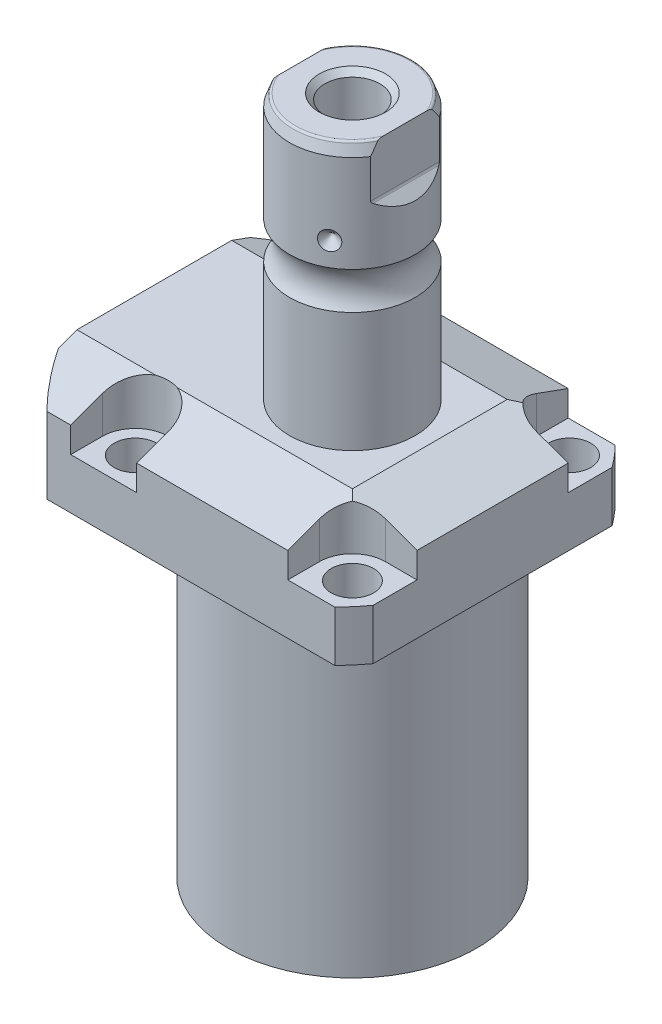
from build123d import *

# Parameters (mm, degrees)
SKETCH1_W                = 70.866
SKETCH1_H                = 85.496
EXTRUDE1_DEPTH           = 104.4448
SKETCH2_OUTSIDE_W        = 117.986
SKETCH2_OUTSIDE_H        = 103.356
SKETCH2_OUTSIDE_R        = 50.8
CUT_EXTRUDE1_DEPTH       = 105.4448
SKETCH3_W                = 45.1992
SKETCH3_H                = 79.4258
FILLET1_R                = 0.381
CUT_EXTRUDE2_DEPTH       = 12.243
CUT_EXTRUDE9_START       = -51.063
CUT_EXTRUDE9_DEPTH       = 87.496
CUT_EXTRUDE7_DEPTH       = 36.433
CUT_EXTRUDE7_DEPTH_BACK  = 36.433
SKETCH10_R               = 1.1811
SKETCH17_W               = 5.3594
SKETCH17_H               = 12.776
HOLE1_AT_2_COUNT         = 2
HOLE1_AT_2_PITCH         = 54.864
HOLE1_AT_3_COUNT         = 2
HOLE1_AT_3_PITCH         = 77.589412886
HOLE1_AT_4_COUNT         = 2
HOLE1_AT_4_PITCH         = 54.864
CHAMFER1_SIZE            = 0.635
FILLET2_R                = 0.635
CIRPATTERN1_COUNT        = 3
CUT_EXTRUDE10_DEPTH      = 36.433
CUT_EXTRUDE10_DEPTH_BACK = 36.433
CHAMFER2_SIZE            = 1.4351


with BuildPart() as part:
    # Sketch1 → Extrude1 (new body)
    with BuildSketch(Plane(origin=(0, 0, 0), x_dir=(0, 0, 1), z_dir=(0, -1, 0))):
        with Locations((0, 7.315)):
            Rectangle(SKETCH1_W, SKETCH1_H)
    extrude(amount=-EXTRUDE1_DEPTH)

    # Sketch2 outside → Cut-Extrude1 (cut, through all)
    with BuildSketch(Plane.XZ):
        with Locations((-7.315, 0)):
            Rectangle(SKETCH2_OUTSIDE_W, SKETCH2_OUTSIDE_H)
        with Locations((-5.4102, 0)):
            Circle(SKETCH2_OUTSIDE_R, mode=Mode.SUBTRACT)
    extrude(amount=-CUT_EXTRUDE1_DEPTH, mode=Mode.SUBTRACT)

    # Sketch3 → Cut-Revolve1 (revolve, cut)
    with BuildSketch(Plane(origin=(0, 0, 0), x_dir=(0, 0, -1), z_dir=(1, 0, 0))):
        with Locations((53.9941, 39.7129)):
            Rectangle(SKETCH3_W, SKETCH3_H)
    revolve(axis=Axis((0, -93.345, 0), (0, 1, 0)), mode=Mode.SUBTRACT)

    # Fillet1
    fillet1_edges = [part.edges().sort_by_distance(p)[0] for p in [
        (0, 79.4258, 31.3945),
    ]]
    fillet(fillet1_edges, radius=FILLET1_R)

    # Sketch4 → Cut-Extrude2 (cut)
    with BuildSketch(Plane(origin=(0, 104.4448, 0), x_dir=(-1, 0, 0), z_dir=(0, 1, 0))):
        with BuildLine():
            Line((-19.1008, -35.433), (-19.1008, -27.432))
            ThreePointArc((-19.1008, -27.432), (-21.540951985, -21.540951985), (-27.432, -19.1008))
            Line((-27.432, -19.1008), (-35.433, -19.1008))
            Line((-35.433, -19.1008), (-35.433, -35.433))
            Line((-35.433, -35.433), (-19.1008, -35.433))
        make_face()
        with BuildLine():
            Line((35.7632, -35.433), (19.1008, -35.433))
            Line((19.1008, -35.433), (19.1008, -27.432))
            ThreePointArc((19.1008, -27.432), (27.432, -19.1008), (35.7632, -27.432))
            Line((35.7632, -27.432), (35.7632, -35.433))
        make_face()
        with BuildLine():
            Line((19.1008, 35.433), (19.1008, 27.432))
            ThreePointArc((19.1008, 27.432), (27.432, 19.1008), (35.7632, 27.432))
            Line((35.7632, 27.432), (35.7632, 35.433))
            Line((35.7632, 35.433), (19.1008, 35.433))
        make_face()
        with BuildLine():
            Line((-27.432, 19.1008), (-35.433, 19.1008))
            Line((-35.433, 19.1008), (-35.433, 35.433))
            Line((-35.433, 35.433), (-19.1008, 35.433))
            Line((-19.1008, 35.433), (-19.1008, 27.432))
            ThreePointArc((-19.1008, 27.432), (-21.540951985, 21.540951985), (-27.432, 19.1008))
        make_face()
    extrude(amount=-CUT_EXTRUDE2_DEPTH, mode=Mode.SUBTRACT)

    # Sketch5 → Cut-Extrude9 (cut)
    with BuildSketch(Plane(origin=(0, 0, 0), x_dir=(0, 0, -1), z_dir=(1, 0, 0)).offset(CUT_EXTRUDE9_START)):
        Polygon((-19.558, 104.4448), (-35.433, 98.666772531), (-35.433, 104.4448), align=None)
    cut_extrude9 = extrude(amount=CUT_EXTRUDE9_DEPTH, mode=Mode.SUBTRACT)

    # Mirror1: Cut-Extrude9 across plane
    add(cut_extrude9.mirror(Plane.XY), mode=Mode.SUBTRACT)

    # Sketch9 → Cut-Extrude7 (cut, two sides)
    with BuildSketch(Plane.XY) as cut_extrude7_sk:
        Polygon((19.558, 104.4448), (35.433, 98.666772531), (35.433, 104.4448), align=None)
    extrude(amount=CUT_EXTRUDE7_DEPTH, mode=Mode.SUBTRACT)
    extrude(cut_extrude7_sk.sketch, amount=-CUT_EXTRUDE7_DEPTH_BACK, mode=Mode.SUBTRACT)

    # Sketch20 → Cut-Revolve4 (revolve, cut)
    with BuildSketch(Plane(origin=(-35.0774, 88.9, -18.1102), x_dir=(0, 1, 0), z_dir=(1, 0, 0)), mode=Mode.PRIVATE) as cut_revolve4_sk:
        Polygon((-9.4742, 38.3413), (-8.0264, 38.3413), (-8.0264, 35.8902), (-7.0104, 35.8902), (-7.0104, 33.8836), (3.9624, 33.8836), (3.9624, 32.639), (-9.4742, 32.639), align=None)
    cut_revolve4 = revolve(cut_revolve4_sk.sketch.rotate(Axis((-35.0774, 81.620304954, 14.5288), (0, 1, 0)), 180), axis=Axis((-35.0774, 81.620304954, 14.5288), (0, 1, 0)), mode=Mode.SUBTRACT)  # turned: the seam where the file's is

    # Mirror10: Cut-Revolve4 across plane
    add(cut_revolve4.mirror(Plane.XY), mode=Mode.SUBTRACT)

    # Sketch15 → Revolve3 (revolve)
    with BuildSketch(Plane(origin=(0, 0, 0), x_dir=(0, 0, -1), z_dir=(1, 0, 0)), mode=Mode.PRIVATE) as revolve3_sk:
        with BuildLine():
            Line((0, 104.4448), (15.875, 104.4448))
            Line((15.875, 104.4448), (15.875, 134.68770643))
            ThreePointArc((15.875, 134.68770643), (14.3256, 139.3948), (15.875, 144.10189357))
            Line((15.875, 144.10189357), (15.875, 168.57979416))
            Line((15.875, 168.57979416), (14.81184082, 171.5008))
            Line((14.81184082, 171.5008), (0, 171.5008))
            Line((0, 171.5008), (0, 104.4448))
        make_face()
    revolve(revolve3_sk.sketch.rotate(Axis((0, 250.290824608, 0), (0, -1, 0)), 180), axis=Axis((0, 250.290824608, 0), (0, -1, 0)))  # turned: the seam where the file's is

    # Sketch17 → Hole1 (revolve, cut)
    with BuildSketch(Plane(origin=(27.432, 92.2018, -27.432), x_dir=(0, 0, 1), z_dir=(1, 0, 0))):
        with Locations((2.6797, 6.388)):
            Rectangle(SKETCH17_W, SKETCH17_H)
    hole1 = revolve(axis=Axis((27.432, -17.7982, -27.432), (0, 1, 0)), mode=Mode.SUBTRACT)

    # Hole1 at 2: Hole1 ×2
    with Locations(*[(0, 0, i * HOLE1_AT_2_PITCH) for i in range(1, HOLE1_AT_2_COUNT)]):
        add(hole1, mode=Mode.SUBTRACT)

    # Hole1 at 3: Hole1 ×2
    with Locations(*[Vector(-0.707106781, 0, 0.707106781) * (i * HOLE1_AT_3_PITCH) for i in range(1, HOLE1_AT_3_COUNT)]):
        add(hole1, mode=Mode.SUBTRACT)

    # Hole1 at 4: Hole1 ×2
    with Locations(*[(-i * HOLE1_AT_4_PITCH, 0, 0) for i in range(1, HOLE1_AT_4_COUNT)]):
        add(hole1, mode=Mode.SUBTRACT)

    # Chamfer1
    chamfer1_edges = [part.edges().sort_by_distance(p)[0] for p in [
        (-35.0774, 81.8896, 15.7734),
        (-35.0774, 81.8896, -15.7734),
    ]]
    chamfer(chamfer1_edges, length=CHAMFER1_SIZE)

    # Sketch21 → Cut-Revolve5 (revolve, cut)
    with BuildSketch(Plane.XZ.offset(-91.9226)):
        Polygon((-50.063, -1.9304), (-49.809, -1.9304), (-49.809, -6.7564), (-47.2563, -7.440393904), (-46.695693904, -8.001), (-30.759, -8.001), (-30.759, -12.9794), (-50.063, -12.9794), align=None)
    cut_revolve5 = revolve(axis=Axis((-57.549532301, 91.9226, -12.9794), (1, 0, 0)), mode=Mode.SUBTRACT)

    # Mirror13: Cut-Revolve5 across plane
    add(cut_revolve5.mirror(Plane.XY), mode=Mode.SUBTRACT)

    # Fillet2
    fillet2_edges = [part.edges().sort_by_distance(p)[0] for p in [
        (0, 171.5008, -14.81184082),
    ]]
    fillet(fillet2_edges, radius=FILLET2_R)

    # Sketch26 → Cut-Revolve7 (revolve, cut)
    with BuildSketch(Plane.XY, mode=Mode.PRIVATE) as cut_revolve7_sk:
        Polygon((-15.875, 152.4758), (-13.462, 150.0628), (-15.875, 150.0628), align=None)
    cut_revolve7 = revolve(cut_revolve7_sk.sketch.rotate(Axis((-39.772000707, 150.0628, 0), (1, 0, 0)), 90), axis=Axis((-39.772000707, 150.0628, 0), (1, 0, 0)), mode=Mode.SUBTRACT)  # turned: the seam where the file's is

    # CirPattern1: Cut-Revolve7 ×3 about axis
    cirpattern1_axis = Axis((0, 250.290824608, 0), (0, 1, 0))
    for i in range(1, CIRPATTERN1_COUNT):
        add(cut_revolve7.rotate(cirpattern1_axis, i * 360 / CIRPATTERN1_COUNT), mode=Mode.SUBTRACT)

    # Sketch27 → Hole2 (revolve, cut)
    with BuildSketch(Plane(origin=(0, 171.5008, 0), x_dir=(0, 0, 1), z_dir=(1, 0, 0))):
        Polygon((0, 0), (0, 28.812118634), (6.9469, 24.638), (6.9469, 0), align=None)
    revolve(axis=Axis((0, 175.744999587, 0), (0, -1, 0)), mode=Mode.SUBTRACT)

    # Sketch29 → Cut-Extrude10 (cut, two sides)
    with BuildSketch(Plane.XY) as cut_extrude10_sk:
        with BuildLine():
            Line((13.284, 171.5008), (13.284, 158.8008))
            ThreePointArc((13.284, 158.8008), (13.342003912, 158.509194643), (13.507185078, 158.261983558))
            Line((13.507185078, 158.261983558), (16.332, 155.437168636))
            Line((16.332, 155.437168636), (16.332, 171.5008))
            Line((16.332, 171.5008), (13.284, 171.5008))
        make_face()
        with BuildLine():
            Line((-16.332, 171.5008), (-13.284, 171.5008))
            Line((-13.284, 171.5008), (-13.284, 158.8008))
            ThreePointArc((-13.284, 158.8008), (-13.342003912, 158.509194643), (-13.507185078, 158.261983558))
            Line((-13.507185078, 158.261983558), (-16.332, 155.437168636))
            Line((-16.332, 155.437168636), (-16.332, 171.5008))
        make_face()
    extrude(amount=CUT_EXTRUDE10_DEPTH, mode=Mode.SUBTRACT)
    extrude(cut_extrude10_sk.sketch, amount=-CUT_EXTRUDE10_DEPTH_BACK, mode=Mode.SUBTRACT)

    # Chamfer2
    chamfer2_edges = [part.edges().sort_by_distance(p)[0] for p in [
        (0, 171.5008, -6.9469),
    ]]
    chamfer(chamfer2_edges, length=CHAMFER2_SIZE)


with BuildPart() as body_2:
    # Sketch10 → Revolve4 (revolve)
    with BuildSketch(Plane(origin=(-35.0774, 88.9, -18.1102), x_dir=(0, 1, 0), z_dir=(1, 0, 0))):
        with Locations((-9.2075, 8.1026)):
            Circle(SKETCH10_R)
    revolve(axis=Axis((-35.0774, 87.86749, -14.5288), (0, 1, 0)))


with BuildPart() as body_3:
    # Mirror12: mirrored copy
    add(body_2.part.mirror(Plane.XY))


solid = Compound([part.part, body_2.part, body_3.part])
